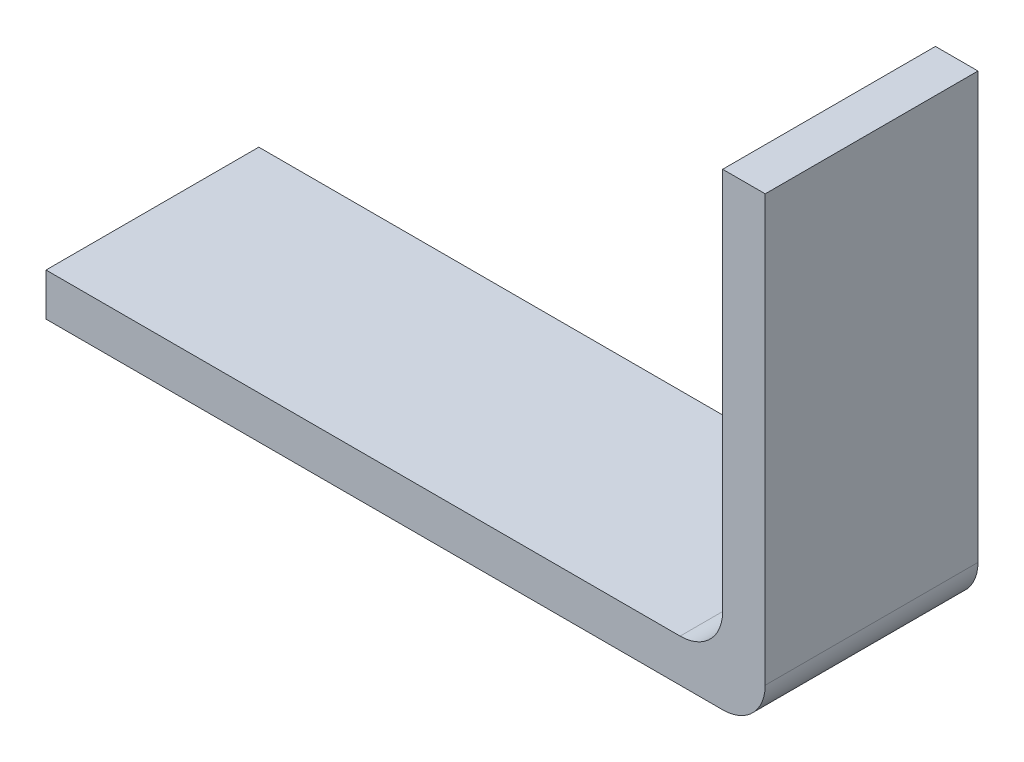
from build123d import *

# Parameters (mm, degrees)
EXTRUDE_THIN1_DEPTH = 5
FILLET1_R           = 1


with BuildPart() as part:
    # Sketch1 → Extrude-Thin1 (new body)
    with BuildSketch(Plane.XY):
        Polygon((0, 0), (15.9, 0), (15.9, 10), (16.9, 10), (16.9, -1), (0, -1), align=None)
    extrude(amount=EXTRUDE_THIN1_DEPTH)

    # Fillet1
    fillet1_edges = [part.edges().sort_by_distance(p)[0] for p in [
        (16.9, -1, 2.5),
        (15.9, 0, 2.5),
    ]]
    fillet(fillet1_edges, radius=FILLET1_R)


solid = part.part
